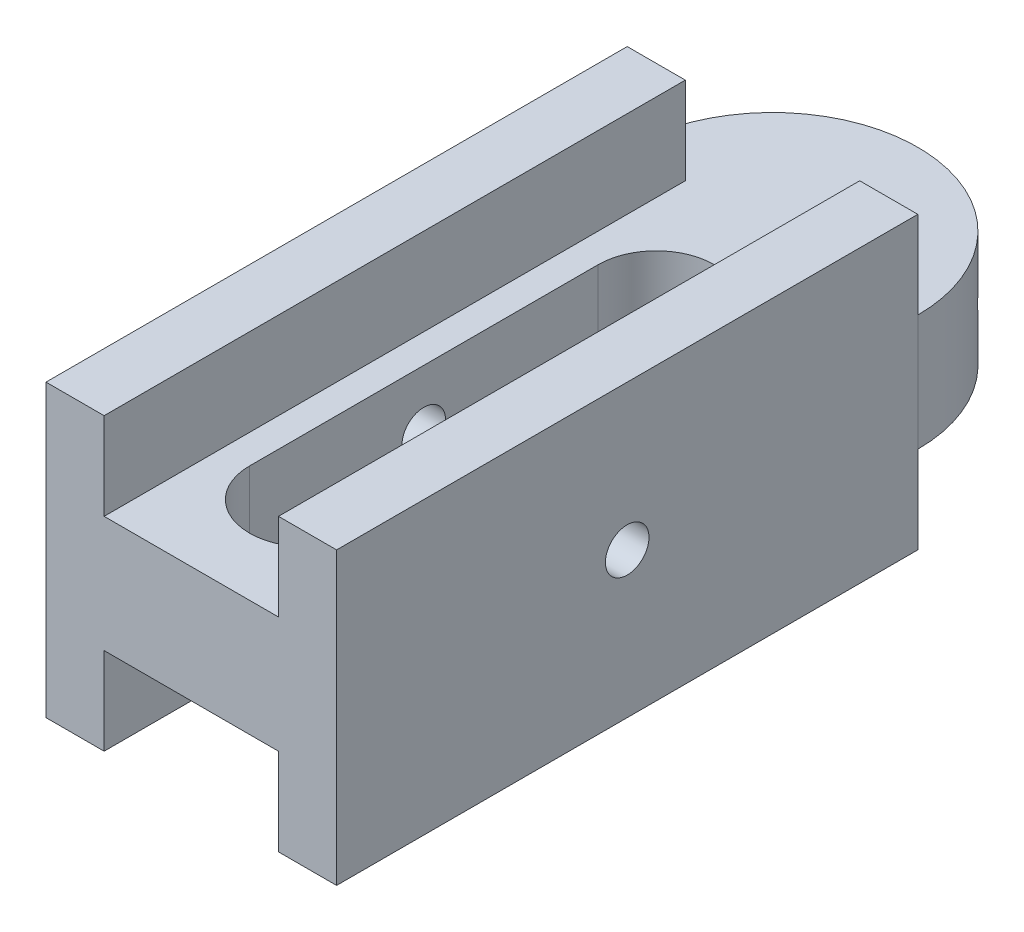
from build123d import *

# Parameters (mm, degrees)
SKETCH1_W                = 15.875
SKETCH1_H                = 15.875
BOSS_EXTRUDE1_DEPTH      = 31.75
BOSS_EXTRUDE3_DEPTH      = 3.175
BOSS_EXTRUDE3_DEPTH_BACK = 3.175
SKETCH4_R                = 1.190625
CUT_EXTRUDE1_DEPTH       = 16.875
SKETCH8_R                = 1.5875
CUT_EXTRUDE3_DEPTH       = 7.9375
SKETCH7_R                = 1.5875
CUT_EXTRUDE4_DEPTH       = 7.9375
SKETCH10_W               = 9.525
SKETCH10_H               = 4.7625
CUT_EXTRUDE5_DEPTH       = 32.75
CUT_EXTRUDE6_DEPTH       = 12.1125


with BuildPart() as part:
    # Sketch1 → Boss-Extrude1 (new body)
    with BuildSketch(Plane.XY):
        Rectangle(SKETCH1_W, SKETCH1_H)
    extrude(amount=BOSS_EXTRUDE1_DEPTH)

    # Sketch3 → Boss-Extrude3 (add, two sides)
    with BuildSketch(Plane(origin=(0, 0, 0), x_dir=(1, 0, 0), z_dir=(0, 1, 0))) as boss_extrude3_sk:
        with BuildLine():
            Line((-7.9375, 0), (7.9375, 0))
            ThreePointArc((7.9375, 0), (0, 7.9375), (-7.9375, 0))
        make_face()
    extrude(amount=BOSS_EXTRUDE3_DEPTH)
    extrude(boss_extrude3_sk.sketch, amount=-BOSS_EXTRUDE3_DEPTH_BACK)

    # Sketch4 → Cut-Extrude1 (cut, through all)
    with BuildSketch(Plane(origin=(7.9375, 0, 0), x_dir=(0, 0, -1), z_dir=(1, 0, 0))):
        with Locations((-15.875, 0)):
            Circle(SKETCH4_R)
    extrude(amount=-CUT_EXTRUDE1_DEPTH, mode=Mode.SUBTRACT)

    # Sketch8 → Cut-Extrude3 (cut)
    with BuildSketch(Plane(origin=(4.72140587, 0, -6.380613831), x_dir=(-0.803856861, 0, -0.594822787), z_dir=(0.594822787, 0, -0.803856861))):
        Circle(SKETCH8_R)
    extrude(amount=-CUT_EXTRUDE3_DEPTH, mode=Mode.SUBTRACT)

    # Sketch7 → Cut-Extrude4 (cut)
    with BuildSketch(Plane(origin=(-6.380613831, 0, -4.72140587), x_dir=(0.594822787, 0, -0.803856861), z_dir=(0.803856861, 0, 0.594822787))):
        Circle(SKETCH7_R)
    extrude(amount=CUT_EXTRUDE4_DEPTH, mode=Mode.SUBTRACT)

    # Sketch10 → Cut-Extrude5 (cut, through all)
    with BuildSketch(Plane(origin=(0, 0, 0), x_dir=(-1, 0, 0), z_dir=(0, 0, -1))):
        with Locations((0, 5.55625)):
            Rectangle(SKETCH10_W, SKETCH10_H)
        with Locations((0, -5.55625)):
            Rectangle(SKETCH10_W, SKETCH10_H)
    extrude(amount=-CUT_EXTRUDE5_DEPTH, mode=Mode.SUBTRACT)

    # Sketch12 → Cut-Extrude6 (cut, through all)
    with BuildSketch(Plane(origin=(0, 3.175, 0), x_dir=(1, 0, 0), z_dir=(0, 1, 0))):
        with BuildLine():
            Line((-3.175, -25.4), (-3.175, -6.35))
            ThreePointArc((-3.175, -6.35), (0, -3.175), (3.175, -6.35))
            Line((3.175, -6.35), (3.175, -25.4))
            ThreePointArc((3.175, -25.4), (0, -28.575), (-3.175, -25.4))
        make_face()
    extrude(amount=-CUT_EXTRUDE6_DEPTH, mode=Mode.SUBTRACT)


solid = part.part
